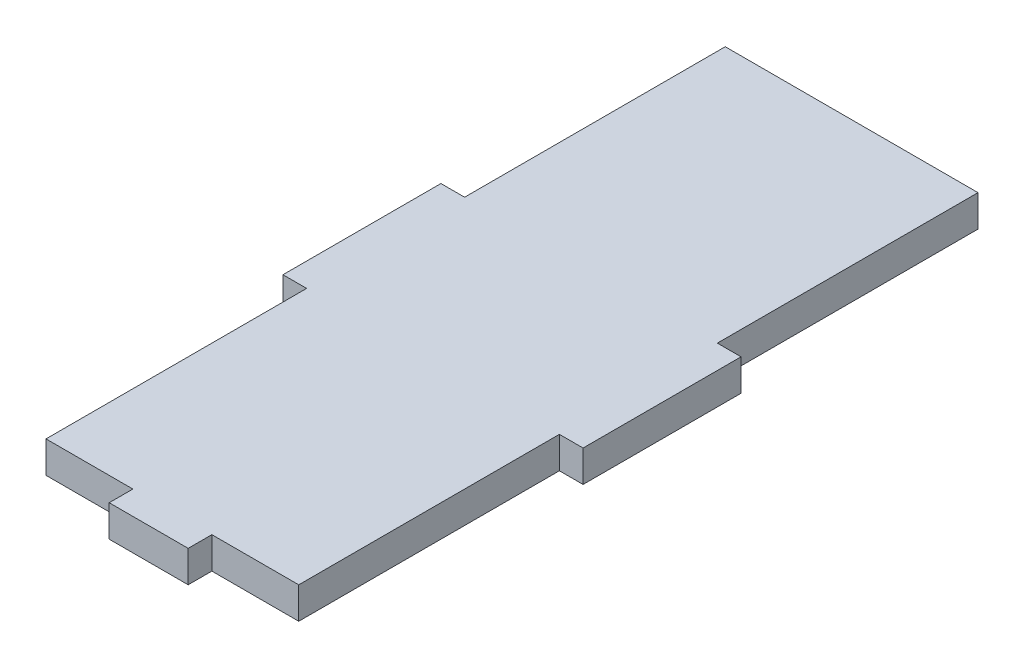
from build123d import *

# Parameters (mm, degrees)
BOSS_EXTRU_1_DEPTH = 4


with BuildPart() as part:
    # Esquisse1 → Boss.-Extru.1 (new body)
    with BuildSketch(Plane(origin=(0, 0, 0), x_dir=(1, 0, 0), z_dir=(0, 1, 0))):
        Polygon((-16, -10), (-16, -43), (-5, -43), (-5, -46), (5, -46), (5, -43), (16, -43), (16, -10), (19, -10), (19, 10), (16, 10), (16, 43), (-16, 43), (-16, 10), (-19, 10), (-19, -10), align=None)
    extrude(amount=BOSS_EXTRU_1_DEPTH)


solid = part.part
